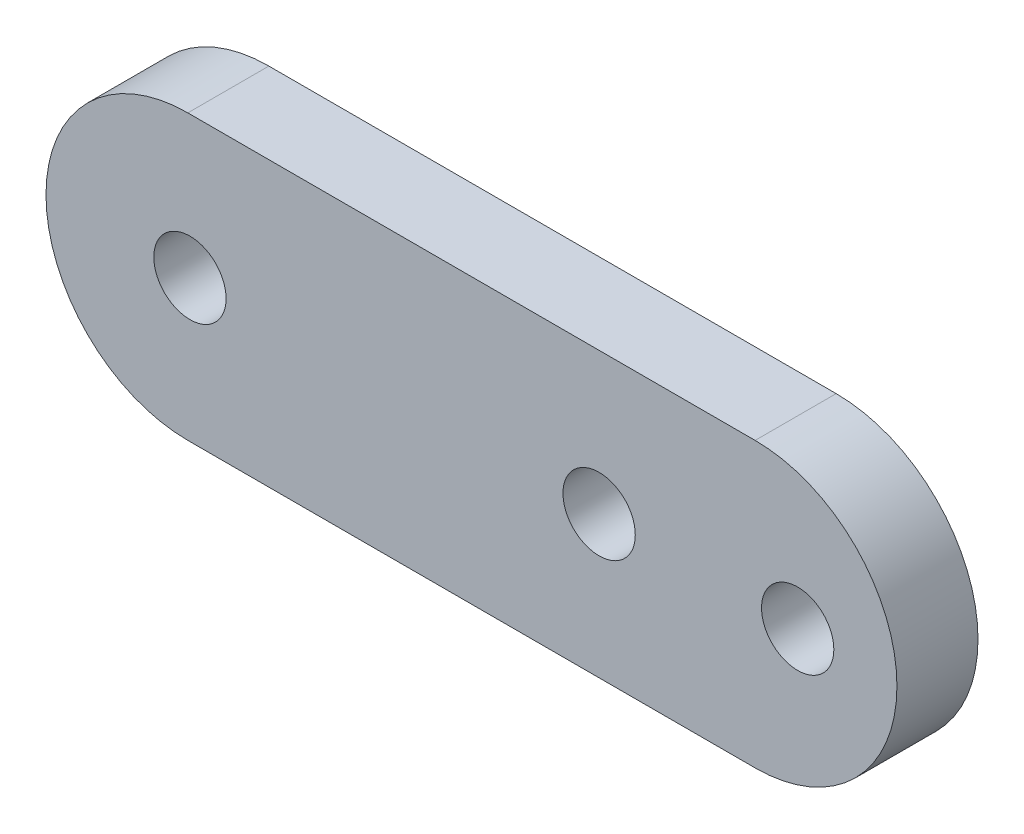
from build123d import *

# Parameters (mm, degrees)
BOSS_EXTRUDE1_DEPTH = 2.8575
SKETCH3_R           = 2.55
CUT_EXTRUDE1_DEPTH  = 6.715
SKETCH4_R           = 2.55
CUT_EXTRUDE2_DEPTH  = 5.715


with BuildPart() as part:
    # Sketch2 → Boss-Extrude1 (new body, symmetric)
    with BuildSketch(Plane.XY):
        with BuildLine():
            Line((-20, 10), (20, 10))
            ThreePointArc((20, 10), (30, 0), (20, -10))
            Line((20, -10), (-20, -10))
            ThreePointArc((-20, -10), (-30, 0), (-20, 10))
        make_face()
    extrude(amount=BOSS_EXTRUDE1_DEPTH, both=True)

    # Sketch3 → Cut-Extrude1 (cut, through all)
    with BuildSketch(Plane.XY.offset(2.8575)):
        with Locations((9, 0)):
            Circle(SKETCH3_R)
        with Locations((23, 0)):
            Circle(SKETCH3_R)
    extrude(amount=-CUT_EXTRUDE1_DEPTH, mode=Mode.SUBTRACT)

    # Sketch4 → Cut-Extrude2 (cut)
    with BuildSketch(Plane.XY.offset(2.8575)):
        with Locations((-19.85, 0)):
            Circle(SKETCH4_R)
    extrude(amount=-CUT_EXTRUDE2_DEPTH, mode=Mode.SUBTRACT)


solid = part.part
